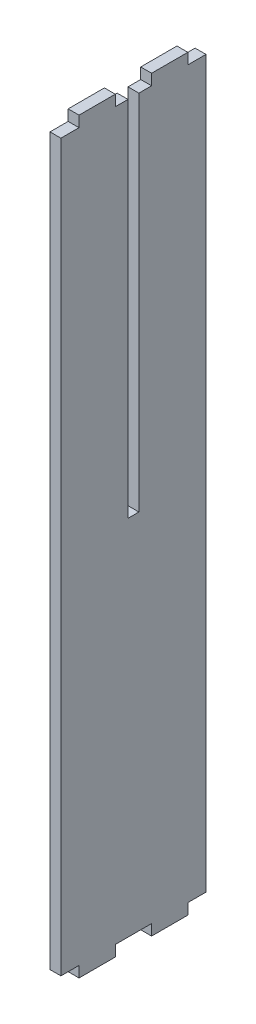
from build123d import *

# Parameters (mm, degrees)
SALIENTE_EXTRUIR1_DEPTH = 1.5
CORTAR_EXTRUIR1_REACH   = 5
CROQUIS2_W              = 3
CROQUIS2_H              = 100


with BuildPart() as part:
    # Croquis1 → Saliente-Extruir1 (new body, symmetric)
    with BuildSketch(Plane(origin=(0, 0, 0), x_dir=(0, 0, -1), z_dir=(1, 0, 0))):
        Polygon((-20, 0), (-15, 0), (-15, -3), (-5, -3), (-5, 0), (5, 0), (5, -3), (15, -3), (15, 0), (20, 0), (20, 200), (15, 200), (15, 203), (5, 203), (5, 200), (-5, 200), (-5, 203), (-15, 203), (-15, 200), (-20, 200), align=None)
    extrude(amount=SALIENTE_EXTRUIR1_DEPTH, both=True)

    # Croquis2 → Cortar-Extruir1 (cut, up to next)
    with BuildSketch(Plane(origin=(1.5, 0, 0), x_dir=(0, 0, -1), z_dir=(1, 0, 0)), mode=Mode.PRIVATE) as cortar_extruir1_sk1:
        with Locations((0, 150)):
            Rectangle(CROQUIS2_W, CROQUIS2_H)
    cortar_extruir1_tool1 = extrude(cortar_extruir1_sk1.sketch, amount=-CORTAR_EXTRUIR1_REACH, mode=Mode.PRIVATE) & part.part
    add(cortar_extruir1_tool1.solids().sort_by_distance((1.5, 150, 0))[0], mode=Mode.SUBTRACT)


solid = part.part
